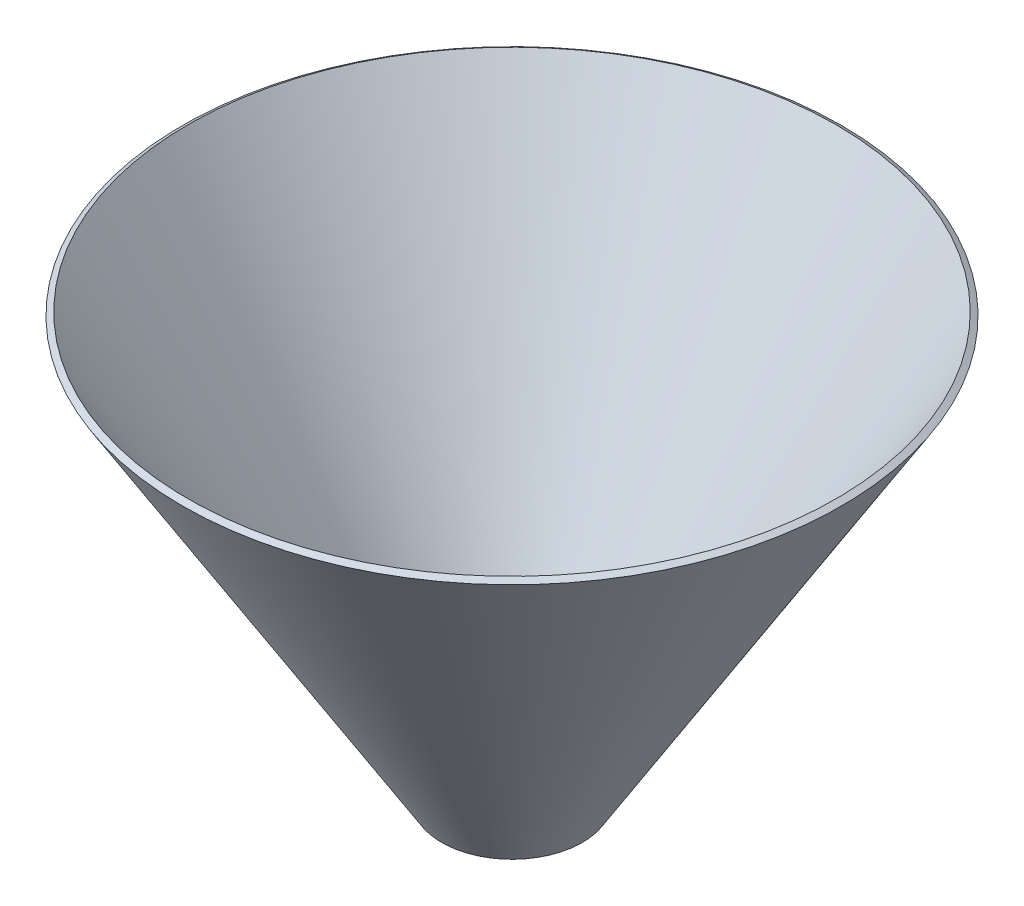
from build123d import *


with BuildPart() as part:
    # Sketch1 → Revolve-Thin1 (revolve)
    with BuildSketch(Plane.XY):
        Polygon((10, 0), (50, 64.975038364), (50.851568443, 64.450794923), (10.851568443, -0.524243442), align=None)
    revolve(axis=Axis((0, 0, 0), (0, 1, 0)))


solid = part.part
